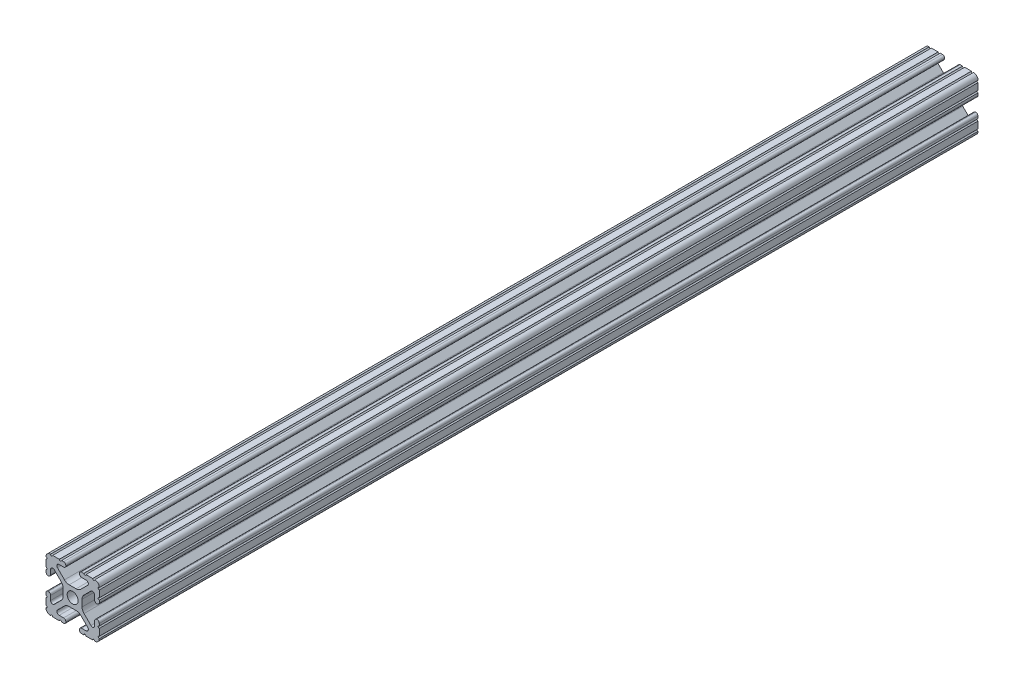
from build123d import *

# Parameters (mm, degrees)
SKETCH1_R               = 2.6035
BOSS_EXTRUDE1_DEPTH     = 209.55
SKETCH4_R               = 3.175
CUT_EXTRUDE3_DEPTH      = 1
CUT_EXTRUDE3_DEPTH_BACK = 26.4


with BuildPart() as part:
    # Sketch1 → Boss-Extrude1 (new body, symmetric)
    with BuildSketch(Plane.XY):
        with BuildLine():
            Line((-7.179650497, -8.645192506), (-3.952270251, -5.423690499))
            ThreePointArc((-3.952270251, -5.423690499), (-2.922936451, -4.736929036), (-1.709253557, -4.4958))
            Line((-1.709253557, -4.4958), (1.709253557, -4.4958))
            ThreePointArc((1.709253557, -4.4958), (2.922936451, -4.736929036), (3.952270251, -5.423690499))
            Line((3.952270251, -5.423690499), (7.179650497, -8.645192506))
            ThreePointArc((7.179650497, -8.645192506), (7.41473083, -9.822813117), (6.416408329, -10.4902))
            Line((6.416408329, -10.4902), (4.287512407, -10.4902))
            ThreePointArc((4.287512407, -10.4902), (3.54574862, -10.79744862), (3.2385, -11.539212407))
            Line((3.2385, -11.539212407), (3.2385, -11.650987593))
            ThreePointArc((3.2385, -11.650987593), (3.54574862, -12.39275138), (4.287512407, -12.7))
            Line((4.287512407, -12.7), (5.317126718, -12.7))
            ThreePointArc((5.317126718, -12.7), (5.825126718, -12.192), (6.333126718, -12.7))
            Line((6.333126718, -12.7), (9.550443118, -12.7))
            ThreePointArc((9.550443118, -12.7), (10.058366869, -12.192000006), (10.566443095, -12.699847501))
            ThreePointArc((10.566443095, -12.699847501), (12.082537762, -12.08250727), (12.699846982, -10.566399977))
            ThreePointArc((12.699846982, -10.566399977), (12.192000006, -10.058323491), (12.7, -9.5504))
            Line((12.7, -9.5504), (12.7, -6.3330836))
            ThreePointArc((12.7, -6.3330836), (12.192, -5.8250836), (12.7, -5.3170836))
            Line((12.7, -5.3170836), (12.7, -4.287469289))
            ThreePointArc((12.7, -4.287469289), (12.39275138, -3.545705502), (11.650987593, -3.238456882))
            Line((11.650987593, -3.238456882), (11.539212407, -3.238456882))
            ThreePointArc((11.539212407, -3.238456882), (10.79744862, -3.545705502), (10.4902, -4.287469289))
            Line((10.4902, -4.287469289), (10.4902, -6.402089023))
            ThreePointArc((10.4902, -6.402089023), (9.856505071, -7.351067942), (8.737131347, -7.129408934))
            Line((8.737131347, -7.129408934), (5.441005833, -3.840816462))
            ThreePointArc((5.441005833, -3.840816462), (4.750877967, -2.809883091), (4.5085, -1.593185507))
            Line((4.5085, -1.593185507), (4.5085, 1.593185507))
            ThreePointArc((4.5085, 1.593185507), (4.750877967, 2.809883091), (5.441005833, 3.840816462))
            Line((5.441005833, 3.840816462), (8.737131347, 7.129408934))
            ThreePointArc((8.737131347, 7.129408934), (9.856505071, 7.351067942), (10.4902, 6.402089023))
            Line((10.4902, 6.402089023), (10.4902, 4.287469289))
            ThreePointArc((10.4902, 4.287469289), (10.79744862, 3.545705502), (11.539212407, 3.238456882))
            Line((11.539212407, 3.238456882), (11.650987593, 3.238456882))
            ThreePointArc((11.650987593, 3.238456882), (12.39275138, 3.545705502), (12.7, 4.287469289))
            Line((12.7, 4.287469289), (12.7, 5.3170836))
            ThreePointArc((12.7, 5.3170836), (12.192, 5.8250836), (12.7, 6.3330836))
            Line((12.7, 6.3330836), (12.7, 9.5504))
            ThreePointArc((12.7, 9.5504), (12.192000006, 10.058323491), (12.699846982, 10.566399977))
            ThreePointArc((12.699846982, 10.566399977), (12.082537762, 12.08250727), (10.566443095, 12.699847501))
            ThreePointArc((10.566443095, 12.699847501), (10.058366869, 12.192000006), (9.550443118, 12.7))
            Line((9.550443118, 12.7), (6.333126718, 12.7))
            ThreePointArc((6.333126718, 12.7), (5.825126718, 12.192), (5.317126718, 12.7))
            Line((5.317126718, 12.7), (4.287512407, 12.7))
            ThreePointArc((4.287512407, 12.7), (3.54574862, 12.39275138), (3.2385, 11.650987593))
            Line((3.2385, 11.650987593), (3.2385, 11.539212407))
            ThreePointArc((3.2385, 11.539212407), (3.54574862, 10.79744862), (4.287512407, 10.4902))
            Line((4.287512407, 10.4902), (6.476788598, 10.4902))
            ThreePointArc((6.476788598, 10.4902), (7.432222385, 9.85140422), (7.207036008, 8.724370562))
            Line((7.207036008, 8.724370562), (3.898272566, 5.423169045))
            ThreePointArc((3.898272566, 5.423169045), (2.869120213, 4.736787962), (1.655778399, 4.4958))
            Line((1.655778399, 4.4958), (-1.655778399, 4.4958))
            ThreePointArc((-1.655778399, 4.4958), (-2.869120213, 4.736787962), (-3.898272566, 5.423169045))
            Line((-3.898272566, 5.423169045), (-7.207036008, 8.724370562))
            ThreePointArc((-7.207036008, 8.724370562), (-7.432222385, 9.85140422), (-6.476788598, 10.4902))
            Line((-6.476788598, 10.4902), (-4.287512407, 10.4902))
            ThreePointArc((-4.287512407, 10.4902), (-3.54574862, 10.79744862), (-3.2385, 11.539212407))
            Line((-3.2385, 11.539212407), (-3.2385, 11.650987593))
            ThreePointArc((-3.2385, 11.650987593), (-3.54574862, 12.39275138), (-4.287512407, 12.7))
            Line((-4.287512407, 12.7), (-5.317126718, 12.7))
            ThreePointArc((-5.317126718, 12.7), (-5.825126718, 12.192), (-6.333126718, 12.7))
            Line((-6.333126718, 12.7), (-9.550443118, 12.7))
            ThreePointArc((-9.550443118, 12.7), (-10.058366869, 12.192000006), (-10.566443095, 12.699847501))
            ThreePointArc((-10.566443095, 12.699847501), (-12.082537762, 12.08250727), (-12.699846982, 10.566399977))
            ThreePointArc((-12.699846982, 10.566399977), (-12.192000006, 10.058323491), (-12.7, 9.5504))
            Line((-12.7, 9.5504), (-12.7, 6.3330836))
            ThreePointArc((-12.7, 6.3330836), (-12.192, 5.8250836), (-12.7, 5.3170836))
            Line((-12.7, 5.3170836), (-12.7, 4.287469289))
            ThreePointArc((-12.7, 4.287469289), (-12.39275138, 3.545705502), (-11.650987593, 3.238456882))
            Line((-11.650987593, 3.238456882), (-11.539212407, 3.238456882))
            ThreePointArc((-11.539212407, 3.238456882), (-10.79744862, 3.545705502), (-10.4902, 4.287469289))
            Line((-10.4902, 4.287469289), (-10.4902, 6.402089023))
            ThreePointArc((-10.4902, 6.402089023), (-9.856505071, 7.351067942), (-8.737131347, 7.129408934))
            Line((-8.737131347, 7.129408934), (-5.441005833, 3.840816462))
            ThreePointArc((-5.441005833, 3.840816462), (-4.750877967, 2.809883091), (-4.5085, 1.593185507))
            Line((-4.5085, 1.593185507), (-4.5085, -1.593185507))
            ThreePointArc((-4.5085, -1.593185507), (-4.750877967, -2.809883091), (-5.441005833, -3.840816462))
            Line((-5.441005833, -3.840816462), (-8.737131347, -7.129408934))
            ThreePointArc((-8.737131347, -7.129408934), (-9.856505071, -7.351067942), (-10.4902, -6.402089023))
            Line((-10.4902, -6.402089023), (-10.4902, -4.287469289))
            ThreePointArc((-10.4902, -4.287469289), (-10.79744862, -3.545705502), (-11.539212407, -3.238456882))
            Line((-11.539212407, -3.238456882), (-11.650987593, -3.238456882))
            ThreePointArc((-11.650987593, -3.238456882), (-12.39275138, -3.545705502), (-12.7, -4.287469289))
            Line((-12.7, -4.287469289), (-12.7, -5.3170836))
            ThreePointArc((-12.7, -5.3170836), (-12.192, -5.8250836), (-12.7, -6.3330836))
            Line((-12.7, -6.3330836), (-12.7, -9.5504))
            ThreePointArc((-12.7, -9.5504), (-12.192000006, -10.058323491), (-12.699846982, -10.566399977))
            ThreePointArc((-12.699846982, -10.566399977), (-12.082537762, -12.08250727), (-10.566443095, -12.699847501))
            ThreePointArc((-10.566443095, -12.699847501), (-10.058366869, -12.192000006), (-9.550443118, -12.7))
            Line((-9.550443118, -12.7), (-6.333126718, -12.7))
            ThreePointArc((-6.333126718, -12.7), (-5.825126718, -12.192), (-5.317126718, -12.7))
            Line((-5.317126718, -12.7), (-4.287512407, -12.7))
            ThreePointArc((-4.287512407, -12.7), (-3.54574862, -12.39275138), (-3.2385, -11.650987593))
            Line((-3.2385, -11.650987593), (-3.2385, -11.539212407))
            ThreePointArc((-3.2385, -11.539212407), (-3.54574862, -10.79744862), (-4.287512407, -10.4902))
            Line((-4.287512407, -10.4902), (-6.416408329, -10.4902))
            ThreePointArc((-6.416408329, -10.4902), (-7.41473083, -9.822813117), (-7.179650497, -8.645192506))
        make_face()
        Circle(SKETCH1_R, mode=Mode.SUBTRACT)
    extrude(amount=BOSS_EXTRUDE1_DEPTH, both=True)

    # Sketch4 → Cut-Extrude3 (cut, two sides)
    with BuildSketch(Plane(origin=(0, 12.7, 0), x_dir=(1, 0, 0), z_dir=(0, 1, 0))) as cut_extrude3_sk:
        with Locations((0, 346.740890105)):
            Circle(SKETCH4_R)
        with Locations((0, -85.059109895)):
            Circle(SKETCH4_R)
    extrude(amount=CUT_EXTRUDE3_DEPTH, mode=Mode.SUBTRACT)
    extrude(cut_extrude3_sk.sketch, amount=-CUT_EXTRUDE3_DEPTH_BACK, mode=Mode.SUBTRACT)


solid = part.part
